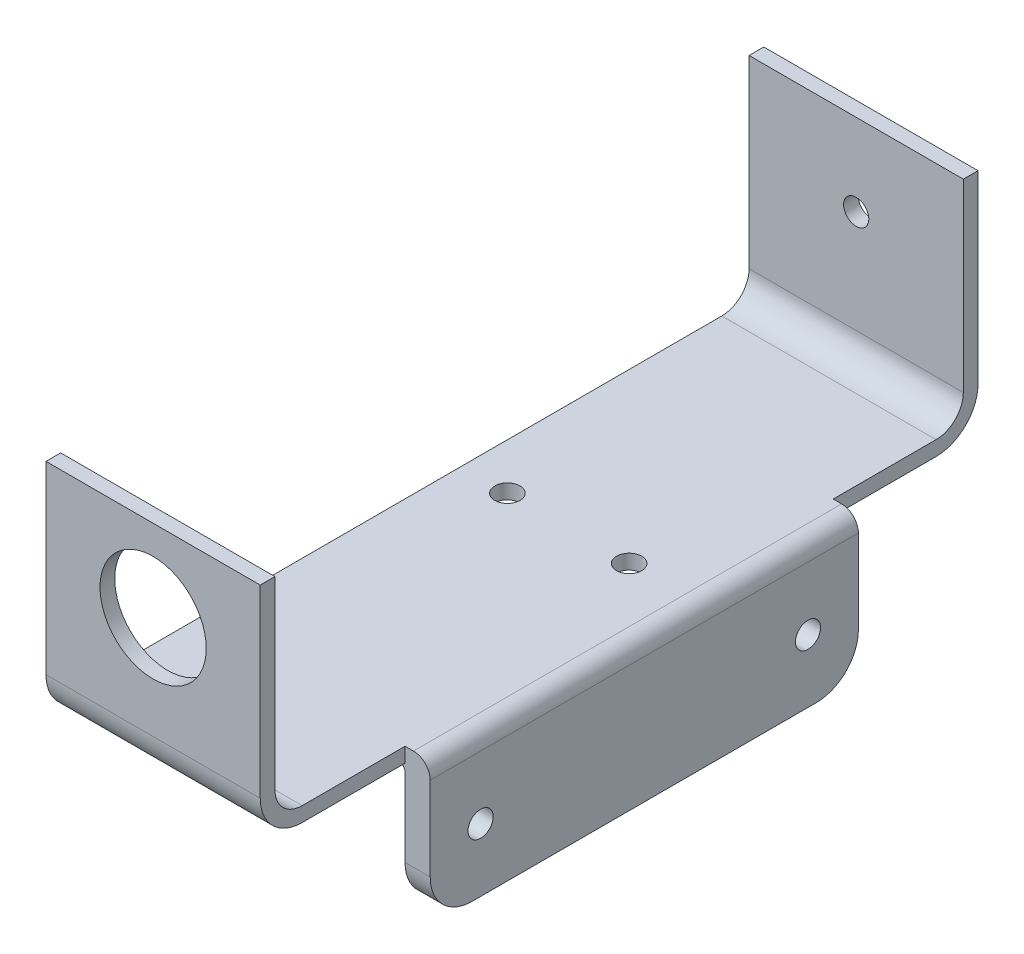
from build123d import *

# Parameters (mm, degrees)
BOSS_EXTRU_1_DEPTH      = 25.52
ESQUISSE2_R             = 6.325
ENL_V_MAT_EXTRU_1_DEPTH = 1.75
ESQUISSE3_R             = 1.5
ENL_V_MAT_EXTRU_2_DEPTH = 25.52
ESQUISSE6_W             = 3
ESQUISSE6_H             = 51
BOSS_EXTRU_2_DEPTH      = 17
CONG_1_R                = 2
CONG_2_R                = 1
ESQUISSE7_R             = 1.5
ENL_V_MAT_EXTRU_3_DEPTH = 29.52
CONG_3_R                = 5
ESQUISSE8_R             = 1.5
ENL_V_MAT_EXTRU_4_DEPTH = 18


with BuildPart() as part:
    # Esquisse1 → Boss.-Extru.1 (new body)
    with BuildSketch(Plane(origin=(0, 0, 0), x_dir=(0, 0, -1), z_dir=(1, 0, 0))):
        with BuildLine():
            Line((0, 27), (0, 5))
            ThreePointArc((0, 5), (1.464466094, 1.464466094), (5, 0))
            Line((5, 0), (80.5, 0))
            ThreePointArc((80.5, 0), (84.035533906, 1.464466094), (85.5, 5))
            Line((85.5, 5), (85.5, 27))
            Line((85.5, 27), (83.75, 27))
            Line((83.75, 27), (83.75, 5))
            ThreePointArc((83.75, 5), (82.798097039, 2.701902961), (80.5, 1.75))
            Line((80.5, 1.75), (5, 1.75))
            ThreePointArc((5, 1.75), (2.701902961, 2.701902961), (1.75, 5))
            Line((1.75, 5), (1.75, 27))
            Line((1.75, 27), (0, 27))
        make_face()
    extrude(amount=BOSS_EXTRU_1_DEPTH)

    # Esquisse2 → Enlèv. mat.-Extru.1 (cut)
    with BuildSketch(Plane.XY):
        with Locations((12.76, 17.25)):
            Circle(ESQUISSE2_R)
    extrude(amount=-ENL_V_MAT_EXTRU_1_DEPTH, mode=Mode.SUBTRACT)

    # Esquisse3 → Enlèv. mat.-Extru.2 (cut)
    with BuildSketch(Plane(origin=(0, 0, -85.5), x_dir=(-1, 0, 0), z_dir=(0, 0, -1))):
        with Locations((-12.76, 17.25)):
            Circle(ESQUISSE3_R)
    extrude(amount=-ENL_V_MAT_EXTRU_2_DEPTH, mode=Mode.SUBTRACT)

    # Esquisse6 → Boss.-Extru.2 (add)
    with BuildSketch(Plane(origin=(0, 1.75, 0), x_dir=(1, 0, 0), z_dir=(0, 1, 0))):
        with Locations((27.02, 42.75)):
            Rectangle(ESQUISSE6_W, ESQUISSE6_H)
    extrude(amount=-BOSS_EXTRU_2_DEPTH)

    # Congé1
    cong_1_edges = [part.edges().sort_by_distance(p)[0] for p in [
        (28.52, 1.75, -42.75),
    ]]
    fillet(cong_1_edges, radius=CONG_1_R)

    # Congé2
    cong_2_edges = [part.edges().sort_by_distance(p)[0] for p in [
        (25.52, 0, -42.75),
    ]]
    fillet(cong_2_edges, radius=CONG_2_R)

    # Esquisse7 → Enlèv. mat.-Extru.3 (cut, through all)
    with BuildSketch(Plane(origin=(28.52, 0, 0), x_dir=(0, 0, -1), z_dir=(1, 0, 0))):
        with Locations((23.25, -7.75)):
            Circle(ESQUISSE7_R)
        with Locations((62.25, -7.75)):
            Circle(ESQUISSE7_R)
    extrude(amount=-ENL_V_MAT_EXTRU_3_DEPTH, mode=Mode.SUBTRACT)

    # Congé3
    cong_3_edges = [part.edges().sort_by_distance(p)[0] for p in [
        (27.02, -15.25, -68.25),
        (27.02, -15.25, -17.25),
    ]]
    fillet(cong_3_edges, radius=CONG_3_R)

    # Esquisse8 → Enlèv. mat.-Extru.4 (cut, through all)
    with BuildSketch(Plane(origin=(0, 1.75, 0), x_dir=(1, 0, 0), z_dir=(0, 1, 0))):
        with Locations((20.01, 49.45)):
            Circle(ESQUISSE8_R)
        with Locations((5.51, 49.45)):
            Circle(ESQUISSE8_R)
    extrude(amount=-ENL_V_MAT_EXTRU_4_DEPTH, mode=Mode.SUBTRACT)


solid = part.part
